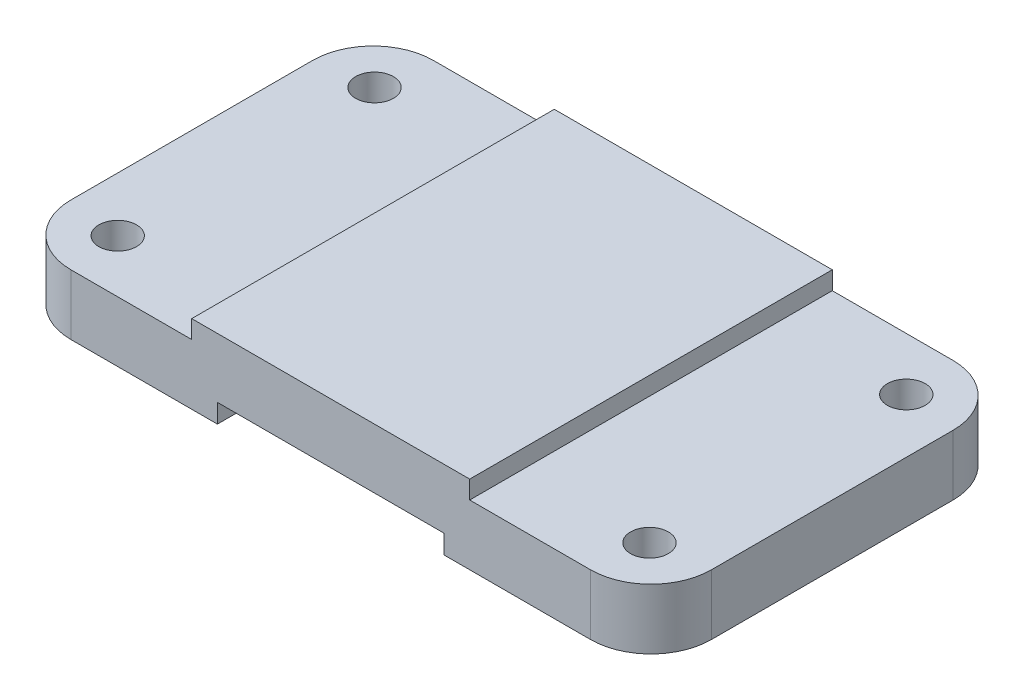
from build123d import *

# Parameters (mm, degrees)
SKETCH1_R           = 3.96875
BOSS_EXTRUDE1_DEPTH = 12.7
SKETCH3_W           = 58.42
SKETCH3_H           = 76.2
BOSS_EXTRUDE2_DEPTH = 3.81
SKETCH4_W           = 47.625
SKETCH4_H           = 76.2
CUT_EXTRUDE1_DEPTH  = 3.9624


with BuildPart() as part:
    # Sketch1 → Boss-Extrude1 (new body)
    with BuildSketch(Plane(origin=(0, 0, 0), x_dir=(1, 0, 0), z_dir=(0, 1, 0))):
        with BuildLine():
            Line((12.7, 76.2), (121.92, 76.2))
            ThreePointArc((121.92, 76.2), (130.900256121, 72.480256121), (134.62, 63.5))
            Line((134.62, 63.5), (134.62, 12.7))
            ThreePointArc((134.62, 12.7), (130.900256121, 3.719743879), (121.92, 0))
            Line((121.92, 0), (12.7, 0))
            ThreePointArc((12.7, 0), (3.719743879, 3.719743879), (0, 12.7))
            Line((0, 12.7), (0, 63.5))
            ThreePointArc((0, 63.5), (3.719743879, 72.480256121), (12.7, 76.2))
        make_face()
        with Locations((11.43, 65.0875)):
            Circle(SKETCH1_R, mode=Mode.SUBTRACT)
        with Locations((123.19, 65.0875)):
            Circle(SKETCH1_R, mode=Mode.SUBTRACT)
        with Locations((123.19, 11.1125)):
            Circle(SKETCH1_R, mode=Mode.SUBTRACT)
        with Locations((11.43, 11.1125)):
            Circle(SKETCH1_R, mode=Mode.SUBTRACT)
    extrude(amount=-BOSS_EXTRUDE1_DEPTH)

    # Sketch3 → Boss-Extrude2 (add)
    with BuildSketch(Plane(origin=(0, 0, 0), x_dir=(1, 0, 0), z_dir=(0, 1, 0))):
        with Locations((67.31, 38.1)):
            Rectangle(SKETCH3_W, SKETCH3_H)
    extrude(amount=BOSS_EXTRUDE2_DEPTH)

    # Sketch4 → Cut-Extrude1 (cut)
    with BuildSketch(Plane.XZ.offset(12.7)):
        with Locations((67.31, -38.1)):
            Rectangle(SKETCH4_W, SKETCH4_H)
    extrude(amount=-CUT_EXTRUDE1_DEPTH, mode=Mode.SUBTRACT)


solid = part.part
